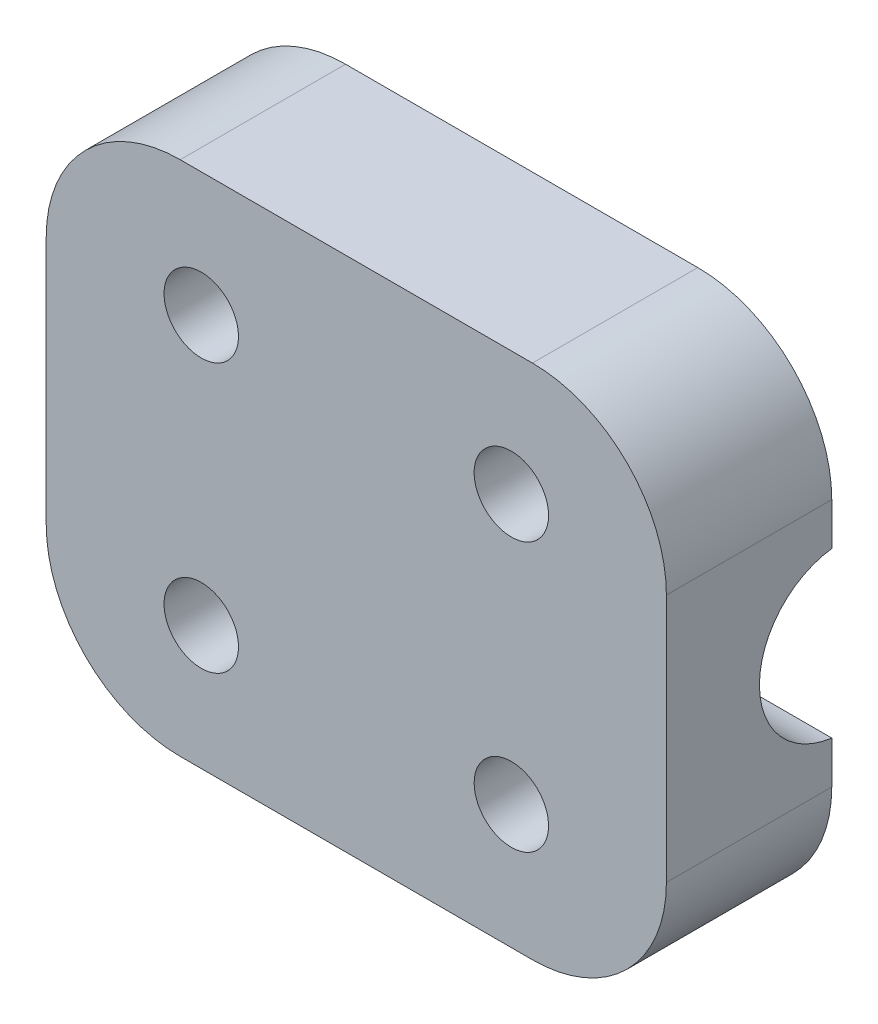
from build123d import *

# Parameters (mm, degrees)
SKETCH1_R           = 1.8
BOSS_EXTRUDE1_DEPTH = 8
SKETCH2_R           = 3.5
CUT_EXTRUDE1_DEPTH  = 31
SKETCH3_R           = 4
CUT_EXTRUDE2_DEPTH  = 15


with BuildPart() as part:
    # Sketch1 → Boss-Extrude1 (new body)
    with BuildSketch(Plane.XY):
        with BuildLine():
            Line((8.519238, 26.5), (-8.519238, 26.5))
            ThreePointArc((-8.519238, 26.5), (-13.101828757, 24.601828757), (-15, 20.019238))
            Line((-15, 20.019238), (-15, 7.980762))
            ThreePointArc((-15, 7.980762), (-13.101828757, 3.398171243), (-8.519238, 1.5))
            Line((-8.519238, 1.5), (8.519238, 1.5))
            ThreePointArc((8.519238, 1.5), (13.101828757, 3.398171243), (15, 7.980762))
            Line((15, 7.980762), (15, 20.019238))
            ThreePointArc((15, 20.019238), (13.101828757, 24.601828757), (8.519238, 26.5))
        make_face()
        with Locations((7.500000742, 20.499999881)):
            Circle(SKETCH1_R, mode=Mode.SUBTRACT)
        with Locations((-7.500000742, 20.499999881)):
            Circle(SKETCH1_R, mode=Mode.SUBTRACT)
        with Locations((-7.500000742, 7.500000119)):
            Circle(SKETCH1_R, mode=Mode.SUBTRACT)
        with Locations((7.500000742, 7.500000119)):
            Circle(SKETCH1_R, mode=Mode.SUBTRACT)
    extrude(amount=-BOSS_EXTRUDE1_DEPTH)

    # Sketch2 → Cut-Extrude1 (cut, through all)
    with BuildSketch(Plane.ZY.offset(15)):
        with Locations((-8.499999447, 14)):
            Circle(SKETCH2_R)
    extrude(amount=-CUT_EXTRUDE1_DEPTH, mode=Mode.SUBTRACT)

    # Sketch3 → Cut-Extrude2 (cut)
    with BuildSketch(Plane(origin=(15, 0, 0), x_dir=(0, 0, -1), z_dir=(1, 0, 0))):
        with Locations((8.499999973, 14)):
            Circle(SKETCH3_R)
    extrude(amount=-CUT_EXTRUDE2_DEPTH, mode=Mode.SUBTRACT)


solid = part.part
